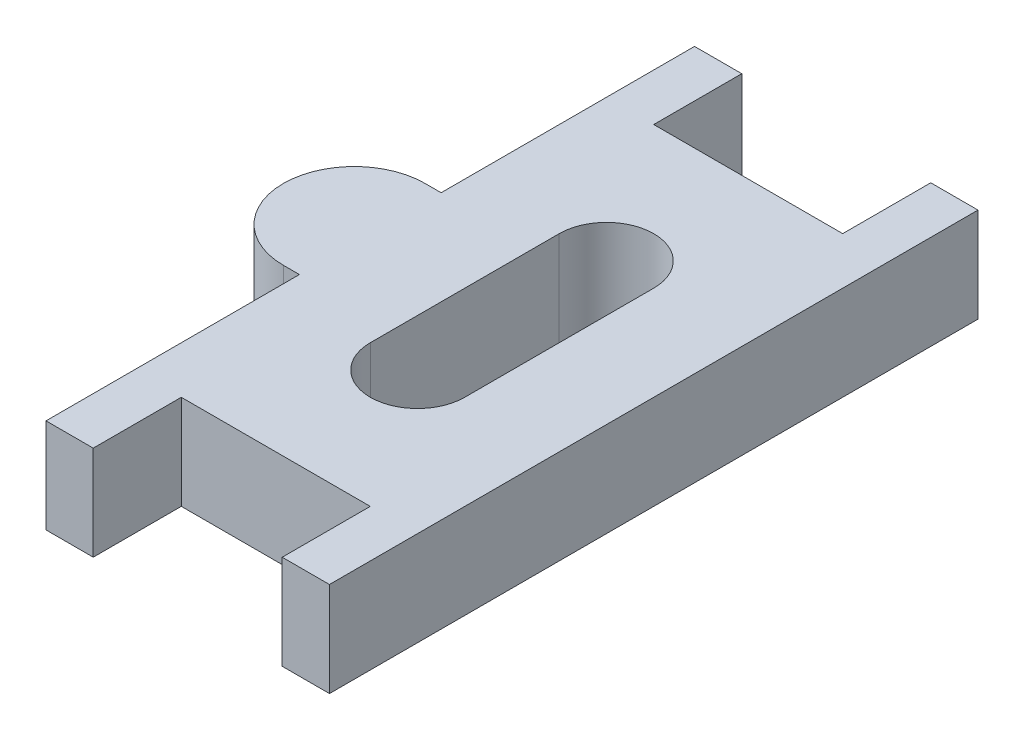
from build123d import *

# Parameters (mm, degrees)
BOSS_EXTRUDE1_DEPTH = 3.175
CUT_EXTRUDE1_REACH  = 5.175


with BuildPart() as part:
    # Sketch2 → Boss-Extrude1 (new body)
    with BuildSketch(Plane(origin=(0, 0, 0), x_dir=(1, 0, 0), z_dir=(0, 1, 0))):
        with BuildLine():
            Line((-3.175, 10.8966), (-3.175, 7.9375))
            Line((-3.175, 7.9375), (3.175, 7.9375))
            Line((3.175, 7.9375), (3.175, 10.8966))
            Line((3.175, 10.8966), (4.7625, 10.8966))
            Line((4.7625, 10.8966), (4.7625, -10.8966))
            Line((4.7625, -10.8966), (3.175, -10.8966))
            Line((3.175, -10.8966), (3.175, -7.9375))
            Line((3.175, -7.9375), (-3.175, -7.9375))
            Line((-3.175, -7.9375), (-3.175, -10.8966))
            Line((-3.175, -10.8966), (-4.7625, -10.8966))
            Line((-4.7625, -10.8966), (-4.7625, -2.38125))
            Line((-4.7625, -2.38125), (-5.30225, -2.38125))
            ThreePointArc((-5.30225, -2.38125), (-7.6835, 0), (-5.30225, 2.38125))
            Line((-5.30225, 2.38125), (-4.7625, 2.38125))
            Line((-4.7625, 2.38125), (-4.7625, 10.8966))
            Line((-4.7625, 10.8966), (-3.175, 10.8966))
        make_face()
    extrude(amount=BOSS_EXTRUDE1_DEPTH)

    # Sketch3 → Cut-Extrude1 (cut, up to next)
    with BuildSketch(Plane(origin=(0, 3.175, 0), x_dir=(1, 0, 0), z_dir=(0, 1, 0)), mode=Mode.PRIVATE) as cut_extrude1_sk1:
        with BuildLine():
            Line((1.5875, 3.175), (1.5875, -3.175))
            ThreePointArc((1.5875, -3.175), (0, -4.7625), (-1.5875, -3.175))
            Line((-1.5875, -3.175), (-1.5875, 3.175))
            ThreePointArc((-1.5875, 3.175), (0, 4.7625), (1.5875, 3.175))
        make_face()
    cut_extrude1_tool1 = extrude(cut_extrude1_sk1.sketch, amount=-CUT_EXTRUDE1_REACH, mode=Mode.PRIVATE) & part.part
    add(cut_extrude1_tool1.solids().sort_by_distance((0, 3.175, 0))[0], mode=Mode.SUBTRACT)


solid = part.part
